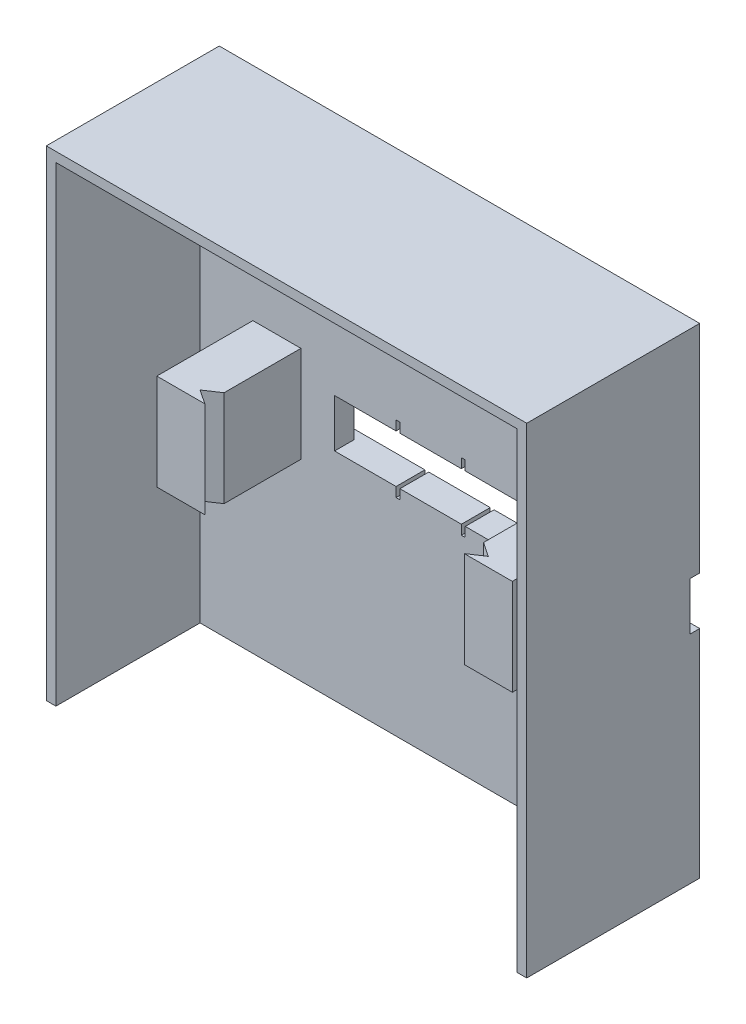
from build123d import *

# Parameters (mm, degrees)
SKICA1_W                 = 50
SKICA1_H                 = 50
P_IDAT_VYSUNUT_M2_DEPTH  = 3
SKICA4_W                 = 20
SKICA4_H                 = 5
ODEBRAT_VYSUNUT_M1_DEPTH = 2
SKICA5_W                 = 50
SKICA5_H                 = 5
ODEBRAT_VYSUNUT_M3_DEPTH = 1
SKICA10_W                = 5
SKICA10_H                = 10
P_IDAT_VYSUNUT_M6_DEPTH  = 10
ODEBRAT_VYSUNUT_M6_DEPTH = 10
P_IDAT_VYSUNUT_M9_DEPTH  = 15
SKICA16_W                = 0.4
SKICA16_H                = 7
ODEBRAT_VYSUNUT_M7_DEPTH = 10
SKICA17_R                = 2
ODEBRAT_VYSUNUT_M8_DEPTH = 4


with BuildPart() as part:
    # Skica1 → Přidat vysunutím2 (new body)
    with BuildSketch(Plane.XY):
        Rectangle(SKICA1_W, SKICA1_H)
    extrude(amount=P_IDAT_VYSUNUT_M2_DEPTH)

    # Skica4 → Odebrat vysunutím1 (cut)
    with BuildSketch(Plane.XY.offset(3)):
        Rectangle(SKICA4_W, SKICA4_H)
    extrude(amount=-ODEBRAT_VYSUNUT_M1_DEPTH, mode=Mode.SUBTRACT)

    # Skica5 → Odebrat vysunutím3 (cut)
    with BuildSketch(Plane(origin=(0, 0, 0), x_dir=(-1, 0, 0), z_dir=(0, 0, -1))):
        Rectangle(SKICA5_W, SKICA5_H)
    extrude(amount=-ODEBRAT_VYSUNUT_M3_DEPTH, mode=Mode.SUBTRACT)

    # Skica10 → Přidat vysunutím6 (add)
    with BuildSketch(Plane.XY.offset(3)):
        with Locations((-16, 0)):
            Rectangle(SKICA10_W, SKICA10_H)
        with Locations((16, 0)):
            Rectangle(SKICA10_W, SKICA10_H)
    extrude(amount=P_IDAT_VYSUNUT_M6_DEPTH)

    # Skica12 → Odebrat vysunutím6 (cut)
    with BuildSketch(Plane(origin=(0, 5, 0), x_dir=(1, 0, 0), z_dir=(0, 1, 0))):
        Polygon((-13.5, -13), (-13.5, -11), (-15, -12), align=None)
        Polygon((13.5, -13), (13.5, -11), (15, -12), align=None)
    extrude(amount=-ODEBRAT_VYSUNUT_M6_DEPTH, mode=Mode.SUBTRACT)

    # Skica14 → Přidat vysunutím9 (add)
    with BuildSketch(Plane.XY.offset(3)):
        Polygon((25, 25), (-25, 25), (-25, -25), (-24, -25), (-24, 24), (24, 24), (24, -25), (25, -25), align=None)
    extrude(amount=P_IDAT_VYSUNUT_M9_DEPTH)

    # Skica16 → Odebrat vysunutím7 (cut)
    with BuildSketch(Plane(origin=(0, 0, 0), x_dir=(-1, 0, 0), z_dir=(0, 0, -1))):
        with Locations((-3.4, 0)):
            Rectangle(SKICA16_W, SKICA16_H)
        with Locations((3.4, 0)):
            Rectangle(SKICA16_W, SKICA16_H)
    extrude(amount=-ODEBRAT_VYSUNUT_M7_DEPTH, mode=Mode.SUBTRACT)

    # Skica17 → Odebrat vysunutím8 (cut)
    with BuildSketch(Plane(origin=(0, 0, 1), x_dir=(-1, 0, 0), z_dir=(0, 0, -1))):
        with Locations((-16, 0)):
            Circle(SKICA17_R)
        with Locations((16, 0)):
            Circle(SKICA17_R)
    extrude(amount=-ODEBRAT_VYSUNUT_M8_DEPTH, mode=Mode.SUBTRACT)


solid = part.part
